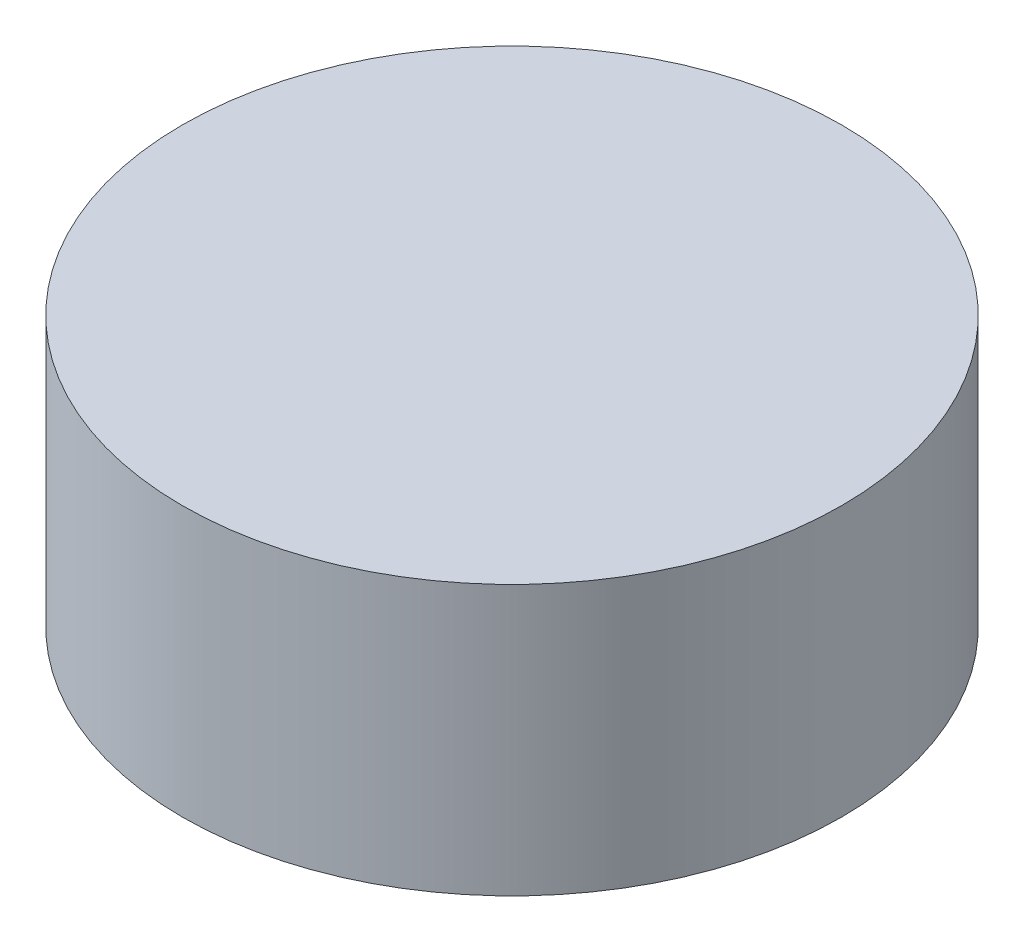
from build123d import *

# Parameters (mm, degrees)
SKETCH1_W = 5.5
SKETCH1_H = 4.5


with BuildPart() as part:
    # Sketch1 → Revolve1 (revolve)
    with BuildSketch(Plane.XY):
        with Locations((2.75, 2.25)):
            Rectangle(SKETCH1_W, SKETCH1_H)
    revolve(axis=Axis((0, 0, 0), (0, 1, 0)))


solid = part.part
